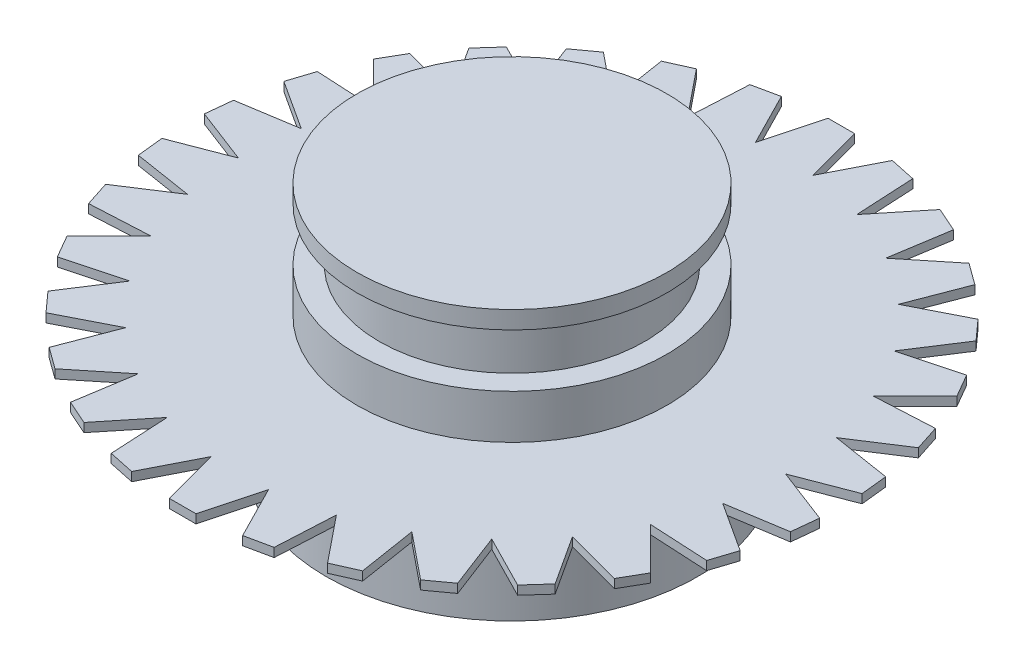
from build123d import *

# Parameters (mm, degrees)
SKETCH1_R                        = 30
TANDHJUL_MAINBODY_DEPTH          = 1
SKETCH2_R                        = 15
TANDHJUL_FISKELINIE_DEPTH        = 20
SKETCH3_R                        = 17.5
TANDHJUL_FISKELINIESTOPPER_DEPTH = 1
T_NDER_DEPTH                     = 1
T_NDERPATTERN_COUNT              = 30
SKETCH11_R                       = 17.5
BOSS_EXTRUDE1_DEPTH              = 5
SKETCH12_R                       = 21
BOSS_EXTRUDE2_DEPTH              = 14
FILLET1_R                        = 2
SKETCH13_R                       = 18.5
CUT_EXTRUDE1_DEPTH               = 12
SKETCH14_R                       = 17
CUT_EXTRUDE2_DEPTH               = 2
SKETCH15_R                       = 23.679719335
CUT_EXTRUDE3_DEPTH               = 10
SKETCH18_R                       = 17.5
BOSS_EXTRUDE3_DEPTH              = 2


with BuildPart() as part:
    # Sketch1 → Tandhjul mainBody (new body)
    with BuildSketch(Plane(origin=(0, 0, 0), x_dir=(1, 0, 0), z_dir=(0, 1, 0))):
        Circle(SKETCH1_R)
    extrude(amount=TANDHJUL_MAINBODY_DEPTH)

    # Sketch2 → Tandhjul fiskelinie (add)
    with BuildSketch(Plane(origin=(0, 1, 0), x_dir=(1, 0, 0), z_dir=(0, 1, 0))):
        Circle(SKETCH2_R)
    extrude(amount=TANDHJUL_FISKELINIE_DEPTH)

    # Sketch3 → Tandhjul fiskelinieStopper (add)
    with BuildSketch(Plane(origin=(0, 21, 0), x_dir=(1, 0, 0), z_dir=(0, 1, 0))):
        Circle(SKETCH3_R)
    extrude(amount=TANDHJUL_FISKELINIESTOPPER_DEPTH)

    # Sketch9 → Tænder (add)
    with BuildSketch(Plane(origin=(0, 1, 0), x_dir=(1, 0, 0), z_dir=(0, 1, 0))):
        Polygon((-1.5, 37.197102186), (-5.038144939, 23.992565508), (0, 23.992565508), (5.038144939, 23.992565508), (1.5, 37.197102186), align=None)
    t_nder = extrude(amount=-T_NDER_DEPTH)

    # TænderPattern: Tænder ×30 about axis
    t_nderpattern_axis = Axis((0, 0, 0), (0, 1, 0))
    for i in range(1, T_NDERPATTERN_COUNT):
        add(t_nder.rotate(t_nderpattern_axis, i * 360 / T_NDERPATTERN_COUNT))

    # Sketch11 → Boss-Extrude1 (add)
    with BuildSketch(Plane(origin=(0, 1, 0), x_dir=(1, 0, 0), z_dir=(0, 1, 0))):
        Circle(SKETCH11_R)
    extrude(amount=BOSS_EXTRUDE1_DEPTH)

    # Sketch12 → Boss-Extrude2 (add)
    with BuildSketch(Plane.XZ):
        Circle(SKETCH12_R)
    extrude(amount=BOSS_EXTRUDE2_DEPTH)

    # Fillet1
    fillet1_edges = [part.edges().sort_by_distance(p)[0] for p in [
        (-21, 0, 0),
    ]]
    fillet(fillet1_edges, radius=FILLET1_R)

    # Sketch13 → Cut-Extrude1 (cut)
    with BuildSketch(Plane.XZ.offset(14)):
        Circle(SKETCH13_R)
    extrude(amount=-CUT_EXTRUDE1_DEPTH, mode=Mode.SUBTRACT)

    # Sketch14 → Cut-Extrude2 (cut)
    with BuildSketch(Plane.XZ.offset(2)):
        Circle(SKETCH14_R)
    extrude(amount=-CUT_EXTRUDE2_DEPTH, mode=Mode.SUBTRACT)

    # Sketch15 → Cut-Extrude3 (cut)
    with BuildSketch(Plane(origin=(0, 22, 0), x_dir=(1, 0, 0), z_dir=(0, 1, 0))):
        with Locations((-1.024461649, -1.098868056)):
            Circle(SKETCH15_R)
    extrude(amount=-CUT_EXTRUDE3_DEPTH, mode=Mode.SUBTRACT)

    # Sketch18 → Boss-Extrude3 (add)
    with BuildSketch(Plane(origin=(0, 12, 0), x_dir=(1, 0, 0), z_dir=(0, 1, 0))):
        Circle(SKETCH18_R)
    extrude(amount=BOSS_EXTRUDE3_DEPTH)


solid = part.part
